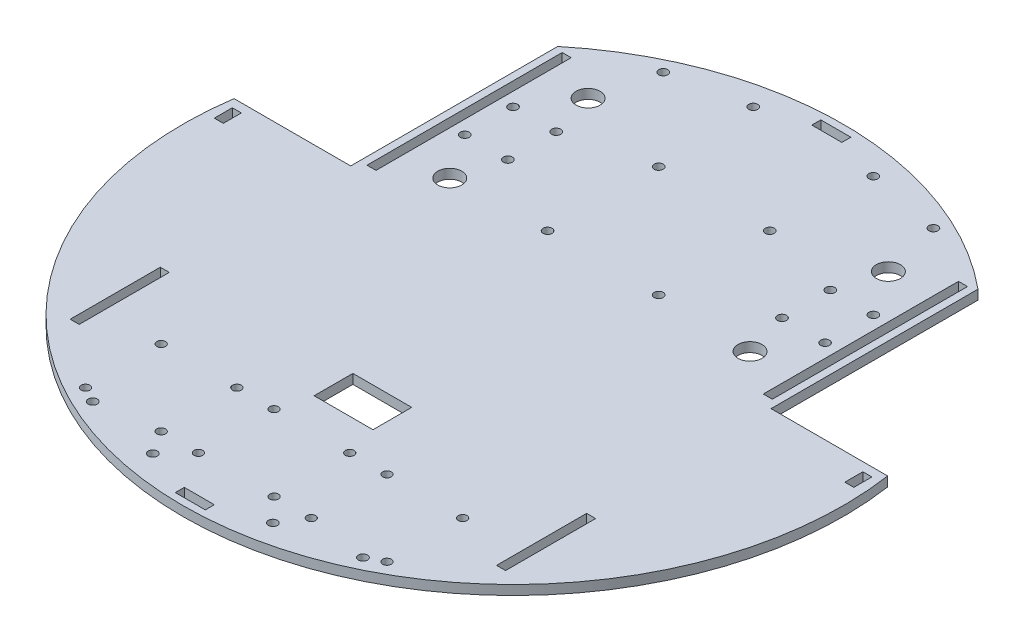
from build123d import *

# Parameters (mm, degrees)
SKETCH_1_R   = 1.5
SKETCH_1_R_2 = 4
SKETCH_1_R_3 = 1.45
SKETCH_1_W   = 10
SKETCH_1_H   = 3
SKETCH_1_W_2 = 19.6
SKETCH_1_H_2 = 12.9
SKETCH_1_W_3 = 3
SKETCH_1_H_3 = 6
SKETCH_1_H_4 = 65
SKETCH_1_H_5 = 30
BASE_DEPTH   = 3.175


with BuildPart() as part:
    # 草图1 → Base (new body)
    with BuildSketch(Plane(origin=(0, 0, 0), x_dir=(1, 0, 0), z_dir=(0, 1, 0))):
        with BuildLine():
            Line((-108.841874295, 15.92), (-70, 15.92))
            Line((-70, 15.92), (-70, 84.852813742))
            ThreePointArc((-70, 84.852813742), (0, 110), (70, 84.852813742))
            Line((70, 84.852813742), (70, 15.92))
            Line((70, 15.92), (108.841874295, 15.92))
            ThreePointArc((108.841874295, 15.92), (0, -110), (-108.841874295, 15.92))
        make_face()
        with Locations((-60, 43.92)):
            Circle(SKETCH_1_R, mode=Mode.SUBTRACT)
        with Locations((-60, 60)):
            Circle(SKETCH_1_R, mode=Mode.SUBTRACT)
        with Locations((-45.65, 60)):
            Circle(SKETCH_1_R, mode=Mode.SUBTRACT)
        with Locations((-45.65, 43.92)):
            Circle(SKETCH_1_R, mode=Mode.SUBTRACT)
        with Locations((60, 60)):
            Circle(SKETCH_1_R, mode=Mode.SUBTRACT)
        with Locations((45.65, 60)):
            Circle(SKETCH_1_R, mode=Mode.SUBTRACT)
        with Locations((45.65, 43.92)):
            Circle(SKETCH_1_R, mode=Mode.SUBTRACT)
        with Locations((60, 43.92)):
            Circle(SKETCH_1_R, mode=Mode.SUBTRACT)
        with Locations((-20, -100)):
            Circle(SKETCH_1_R, mode=Mode.SUBTRACT)
        with Locations((20, -100)):
            Circle(SKETCH_1_R, mode=Mode.SUBTRACT)
        with Locations((20, 100)):
            Circle(SKETCH_1_R, mode=Mode.SUBTRACT)
        with Locations((-20, 100)):
            Circle(SKETCH_1_R, mode=Mode.SUBTRACT)
        with Locations((-50, 75)):
            Circle(SKETCH_1_R_2, mode=Mode.SUBTRACT)
        with Locations((50, 75)):
            Circle(SKETCH_1_R_2, mode=Mode.SUBTRACT)
        with Locations((-18.5, 67)):
            Circle(SKETCH_1_R, mode=Mode.SUBTRACT)
        with Locations((-18.5, 30)):
            Circle(SKETCH_1_R, mode=Mode.SUBTRACT)
        with Locations((18.5, 30)):
            Circle(SKETCH_1_R, mode=Mode.SUBTRACT)
        with Locations((18.5, 67)):
            Circle(SKETCH_1_R, mode=Mode.SUBTRACT)
        with Locations((-12.6, -67)):
            Circle(SKETCH_1_R_3, mode=Mode.SUBTRACT)
        with Locations((-12.6, -92.2)):
            Circle(SKETCH_1_R_3, mode=Mode.SUBTRACT)
        with Locations((12.6, -92.2)):
            Circle(SKETCH_1_R_3, mode=Mode.SUBTRACT)
        with Locations((12.6, -67)):
            Circle(SKETCH_1_R_3, mode=Mode.SUBTRACT)
        with Locations((-45, 95)):
            Circle(SKETCH_1_R, mode=Mode.SUBTRACT)
        with Locations((45, 95)):
            Circle(SKETCH_1_R, mode=Mode.SUBTRACT)
        with Locations((45, -95)):
            Circle(SKETCH_1_R, mode=Mode.SUBTRACT)
        with Locations((-45, -95)):
            Circle(SKETCH_1_R, mode=Mode.SUBTRACT)
        with Locations((-50.2, -67)):
            Circle(SKETCH_1_R_3, mode=Mode.SUBTRACT)
        with Locations((-50.2, -92.2)):
            Circle(SKETCH_1_R_3, mode=Mode.SUBTRACT)
        with Locations((-25, -67)):
            Circle(SKETCH_1_R_3, mode=Mode.SUBTRACT)
        with Locations((-25, -92.2)):
            Circle(SKETCH_1_R_3, mode=Mode.SUBTRACT)
        with Locations((50.2, -92.2)):
            Circle(SKETCH_1_R_3, mode=Mode.SUBTRACT)
        with Locations((25, -92.2)):
            Circle(SKETCH_1_R_3, mode=Mode.SUBTRACT)
        with Locations((25, -67)):
            Circle(SKETCH_1_R_3, mode=Mode.SUBTRACT)
        with Locations((50.2, -67)):
            Circle(SKETCH_1_R_3, mode=Mode.SUBTRACT)
        with Locations((-50, 28.92)):
            Circle(SKETCH_1_R_2, mode=Mode.SUBTRACT)
        with Locations((50, 28.92)):
            Circle(SKETCH_1_R_2, mode=Mode.SUBTRACT)
        with Locations((0, -106)):
            Rectangle(SKETCH_1_W, SKETCH_1_H, mode=Mode.SUBTRACT)
        with Locations((0, -50)):
            Rectangle(SKETCH_1_W_2, SKETCH_1_H_2, mode=Mode.SUBTRACT)
        with Locations((0, 106)):
            Rectangle(SKETCH_1_W, SKETCH_1_H, mode=Mode.SUBTRACT)
        with Locations((105, 10)):
            Rectangle(SKETCH_1_W_3, SKETCH_1_H_3, mode=Mode.SUBTRACT)
        with Locations((-105, 10)):
            Rectangle(SKETCH_1_W_3, SKETCH_1_H_3, mode=Mode.SUBTRACT)
        with Locations((66, 51.352813742)):
            Rectangle(SKETCH_1_W_3, SKETCH_1_H_4, mode=Mode.SUBTRACT)
        with Locations((-66, 51.352813742)):
            Rectangle(SKETCH_1_W_3, SKETCH_1_H_4, mode=Mode.SUBTRACT)
        with Locations((71, -60)):
            Rectangle(SKETCH_1_W_3, SKETCH_1_H_5, mode=Mode.SUBTRACT)
        with Locations((-71, -60)):
            Rectangle(SKETCH_1_W_3, SKETCH_1_H_5, mode=Mode.SUBTRACT)
    extrude(amount=BASE_DEPTH)


solid = part.part
